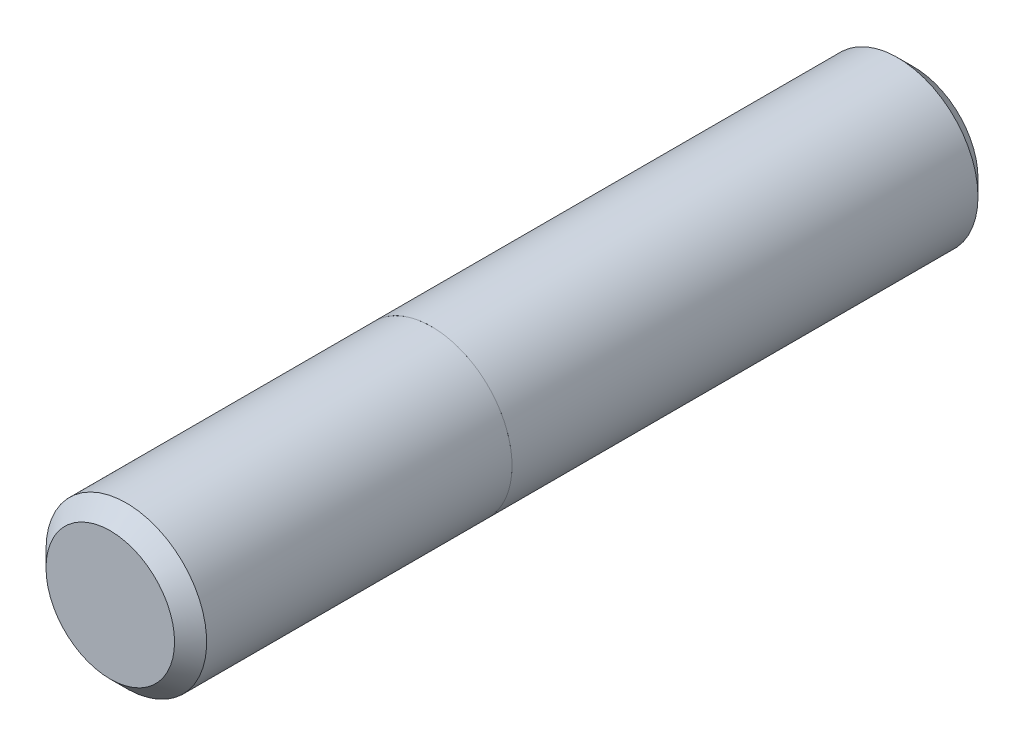
from build123d import *

# Parameters (mm, degrees)
SKIZZE1_R                       = 5
AUFSATZ_LINEAR_AUSTRAGEN1_DEPTH = 50
FASE1_SIZE                      = 1
SZKIC1_OUTSIDE_W                = 22.392
SZKIC1_OUTSIDE_H                = 22.392
SZKIC1_OUTSIDE_R                = 4.999
WYTNIJ_WYCI_GNI_CIE1_DEPTH      = 21


with BuildPart() as part:
    # Skizze1 → Aufsatz-Linear austragen1 (new body)
    with BuildSketch(Plane.XY):
        Circle(SKIZZE1_R)
    extrude(amount=AUFSATZ_LINEAR_AUSTRAGEN1_DEPTH)

    # Fase1
    fase1_edges = [part.edges().sort_by_distance(p)[0] for p in [
        (-5, 0, 0),
        (-5, 0, 50),
    ]]
    chamfer(fase1_edges, length=FASE1_SIZE)

    # Szkic1 outside → Wytnij-wyciągnięcie1 (cut, through all)
    with BuildSketch(Plane.XY.offset(30)):
        Rectangle(SZKIC1_OUTSIDE_W, SZKIC1_OUTSIDE_H)
        with Locations(Location((0, 0, 0), (0, 0, 180))):  # turned: the seam where the file's is
            Circle(SZKIC1_OUTSIDE_R, mode=Mode.SUBTRACT)
    extrude(amount=WYTNIJ_WYCI_GNI_CIE1_DEPTH, mode=Mode.SUBTRACT)


solid = part.part
